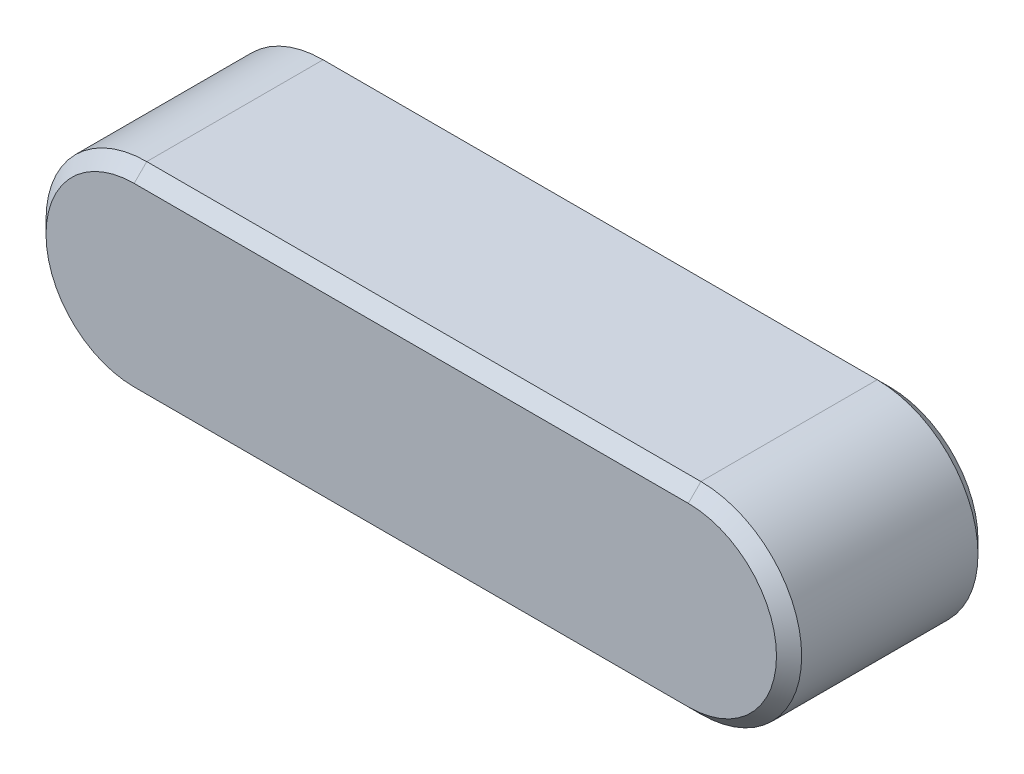
from build123d import *

# Parameters (mm, degrees)
P_IDAT_VYSUNUT_M1_DEPTH = 8
ZKOSEN_1_SIZE           = 0.5


with BuildPart() as part:
    # Skica1 → Přidat vysunutím1 (new body)
    with BuildSketch(Plane.XY):
        with BuildLine():
            Line((0, 4), (22, 4))
            ThreePointArc((22, 4), (26, 0), (22, -4))
            Line((22, -4), (0, -4))
            ThreePointArc((0, -4), (-4, 0), (0, 4))
        make_face()
    extrude(amount=P_IDAT_VYSUNUT_M1_DEPTH)

    # Zkosení1
    zkosen_1_edges = [part.edges().sort_by_distance(p)[0] for p in [
        (26, 0, 8),
        (11, 4, 8),
        (-4, 0, 8),
        (11, 4, 0),
        (26, 0, 0),
        (11, -4, 0),
        (-4, 0, 0),
        (11, -4, 8),
    ]]
    chamfer(zkosen_1_edges, length=ZKOSEN_1_SIZE)


solid = part.part
